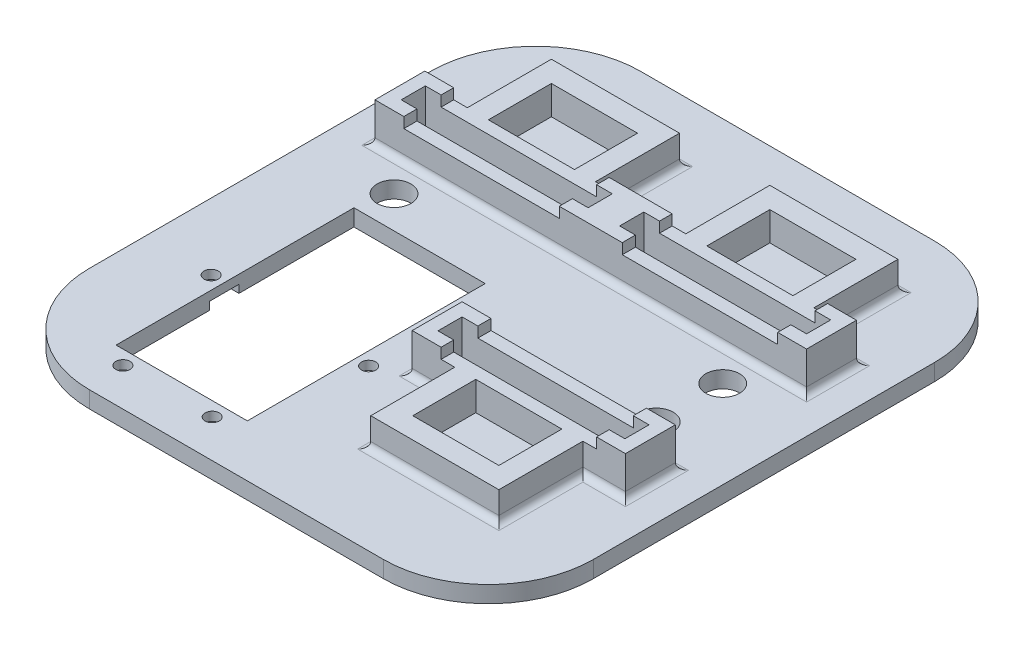
from build123d import *

# Parameters (mm, degrees)
W_TOP_DEPTH         = 3.175
SKETCH3_W           = 35.6
SKETCH3_H           = 4.6
SKETCH3_W_2         = 16.4
SKETCH3_H_2         = 12
A_HOLDERS_DEPTH     = 5.5
HOLDER_CHAMFER_R    = 1.25
A_CLAMP_DEPTH       = 2
SKETCH12_R          = 1.35
SKETCH12_W          = 25
SKETCH12_H          = 45.3
A_HOLES_DEPTH       = 3.175
A_HOLES_GUIDE_DEPTH = 1.5
SKETCH15_R          = 3.225
TENDON_HOLES_DEPTH  = 3.175


with BuildPart() as part:
    # Sketch1 → w_top (new body)
    with BuildSketch(Plane(origin=(0, 0, 0), x_dir=(1, 0, 0), z_dir=(0, 1, 0))):
        with BuildLine():
            Line((-48, -35), (-48, 30))
            ThreePointArc((-48, 30), (-42.142135624, 44.142135624), (-28, 50))
            Line((-28, 50), (28, 50))
            ThreePointArc((28, 50), (42.142135624, 44.142135624), (48, 30))
            Line((48, 30), (48, -35))
            ThreePointArc((48, -35), (42.142135624, -49.142135624), (28, -55))
            Line((28, -55), (-28, -55))
            ThreePointArc((-28, -55), (-42.142135624, -49.142135624), (-48, -35))
        make_face()
    extrude(amount=W_TOP_DEPTH)

    # Sketch3 → a_holders (add)
    with BuildSketch(Plane(origin=(0, 3.175, 0), x_dir=(1, 0, 0), z_dir=(0, 1, 0))):
        Polygon((-33, 22), (-33, 38), (-8.6, 38), (-8.6, 22), (8.6, 22), (8.6, 38), (33, 38), (33, 22), (41.1, 22), (41.1, 12.5), (-41.1, 12.5), (-41.1, 22), align=None)
        with Locations((20.8, 17.3)):
            Rectangle(SKETCH3_W, SKETCH3_H, mode=Mode.SUBTRACT)
        with Locations((-20.8, 17.3)):
            Rectangle(SKETCH3_W, SKETCH3_H, mode=Mode.SUBTRACT)
        with Locations((-20.8, 28)):
            Rectangle(SKETCH3_W_2, SKETCH3_H_2, mode=Mode.SUBTRACT)
        with Locations((20.8, 28)):
            Rectangle(SKETCH3_W_2, SKETCH3_H_2, mode=Mode.SUBTRACT)
        Polygon((8.6, -22), (0.5, -22), (0.5, -12.5), (41.1, -12.5), (41.1, -22), (33, -22), (33, -38), (8.6, -38), align=None)
        with Locations((20.8, -17.3)):
            Rectangle(SKETCH3_W, SKETCH3_H, mode=Mode.SUBTRACT)
        with Locations((20.8, -28)):
            Rectangle(SKETCH3_W_2, SKETCH3_H_2, mode=Mode.SUBTRACT)
    extrude(amount=A_HOLDERS_DEPTH)

    # holder_chamfer
    holder_chamfer_edges = [part.edges().sort_by_distance(p)[0] for p in [
        (0.5, 3.175, 17.25),
        (20.8, 3.175, 12.5),
        (41.1, 3.175, 17.25),
        (37.05, 3.175, 22),
        (33, 3.175, 30),
        (20.8, 3.175, 38),
        (8.6, 3.175, 30),
        (4.55, 3.175, 22),
        (41.1, 3.175, -17.25),
        (0, 3.175, -12.5),
        (-41.1, 3.175, -17.25),
        (-37.05, 3.175, -22),
        (-33, 3.175, -30),
        (-20.8, 3.175, -38),
        (-8.6, 3.175, -30),
        (0, 3.175, -22),
        (8.6, 3.175, -30),
        (20.8, 3.175, -38),
        (33, 3.175, -30),
        (37.05, 3.175, -22),
    ]]
    fillet(holder_chamfer_edges, radius=HOLDER_CHAMFER_R)

    # Sketch14 → a_clamp (add)
    with BuildSketch(Plane(origin=(0, 8.675, 0), x_dir=(1, 0, 0), z_dir=(0, 1, 0))):
        Polygon((-35.6, 19.6), (-35.6, 22), (-41.1, 22), (-41.1, 12.5), (-35.6, 12.5), (-35.6, 15), (-38.6, 15), (-38.6, 19.6), align=None)
        Polygon((-3, 19.6), (-6, 19.6), (-6, 22), (6, 22), (6, 19.6), (3, 19.6), (3, 15), (6, 15), (6, 12.5), (-6, 12.5), (-6, 15), (-3, 15), align=None)
        Polygon((38.6, 19.6), (35.6, 19.6), (35.6, 22), (41.1, 22), (41.1, 12.5), (35.6, 12.5), (35.6, 15), (38.6, 15), align=None)
        Polygon((0.5, -12.5), (6, -12.5), (6, -15), (3, -15), (3, -19.6), (6, -19.6), (6, -22), (0.5, -22), align=None)
        Polygon((35.6, -19.6), (35.6, -22), (41.1, -22), (41.1, -12.5), (35.6, -12.5), (35.6, -15), (38.6, -15), (38.6, -19.6), align=None)
    extrude(amount=A_CLAMP_DEPTH)

    # Sketch12 → a_holes (cut)
    with BuildSketch(Plane(origin=(0, 3.175, 0), x_dir=(1, 0, 0), z_dir=(0, 1, 0))):
        with Locations((-28.8, -47.8)):
            Circle(SKETCH12_R)
        with Locations((-11.8, -47.8)):
            Circle(SKETCH12_R)
        with Locations((-35.3, -24.5)):
            Circle(SKETCH12_R)
        with Locations((-5.3, -24.5)):
            Circle(SKETCH12_R)
        with Locations((-20.3, -22.45)):
            Rectangle(SKETCH12_W, SKETCH12_H)
    extrude(amount=-A_HOLES_DEPTH, mode=Mode.SUBTRACT)

    # Sketch13 → a_holes guide (cut)
    with BuildSketch(Plane.XZ):
        with BuildLine():
            Line((-31.6, 47.8), (-31.6, 45.1))
            Line((-31.6, 45.1), (-26, 45.1))
            Line((-26, 45.1), (-26, 47.8))
            ThreePointArc((-26, 47.8), (-28.8, 50.6), (-31.6, 47.8))
        make_face()
        with BuildLine():
            Line((-35.3, 27.3), (-32.8, 27.3))
            Line((-32.8, 27.3), (-32.8, 21.7))
            Line((-32.8, 21.7), (-35.3, 21.7))
            ThreePointArc((-35.3, 21.7), (-38.1, 24.5), (-35.3, 27.3))
        make_face()
        with BuildLine():
            Line((-7.8, 21.7), (-5.3, 21.7))
            ThreePointArc((-5.3, 21.7), (-2.5, 24.5), (-5.3, 27.3))
            Line((-5.3, 27.3), (-7.8, 27.3))
            Line((-7.8, 27.3), (-7.8, 21.7))
        make_face()
        with BuildLine():
            Line((-14.6, 45.1), (-14.6, 47.8))
            ThreePointArc((-14.6, 47.8), (-11.8, 50.6), (-9, 47.8))
            Line((-9, 47.8), (-9, 45.1))
            Line((-9, 45.1), (-14.6, 45.1))
        make_face()
    extrude(amount=-A_HOLES_GUIDE_DEPTH, mode=Mode.SUBTRACT)

    # Sketch15 → tendon holes (cut)
    with BuildSketch(Plane(origin=(0, 3.175, 0), x_dir=(1, 0, 0), z_dir=(0, 1, 0))):
        with Locations((-31.3, 6.33)):
            Circle(SKETCH15_R)
        with Locations((31.3, 6.33)):
            Circle(SKETCH15_R)
        with Locations((31.3, -6.33)):
            Circle(SKETCH15_R)
    extrude(amount=-TENDON_HOLES_DEPTH, mode=Mode.SUBTRACT)


solid = part.part
